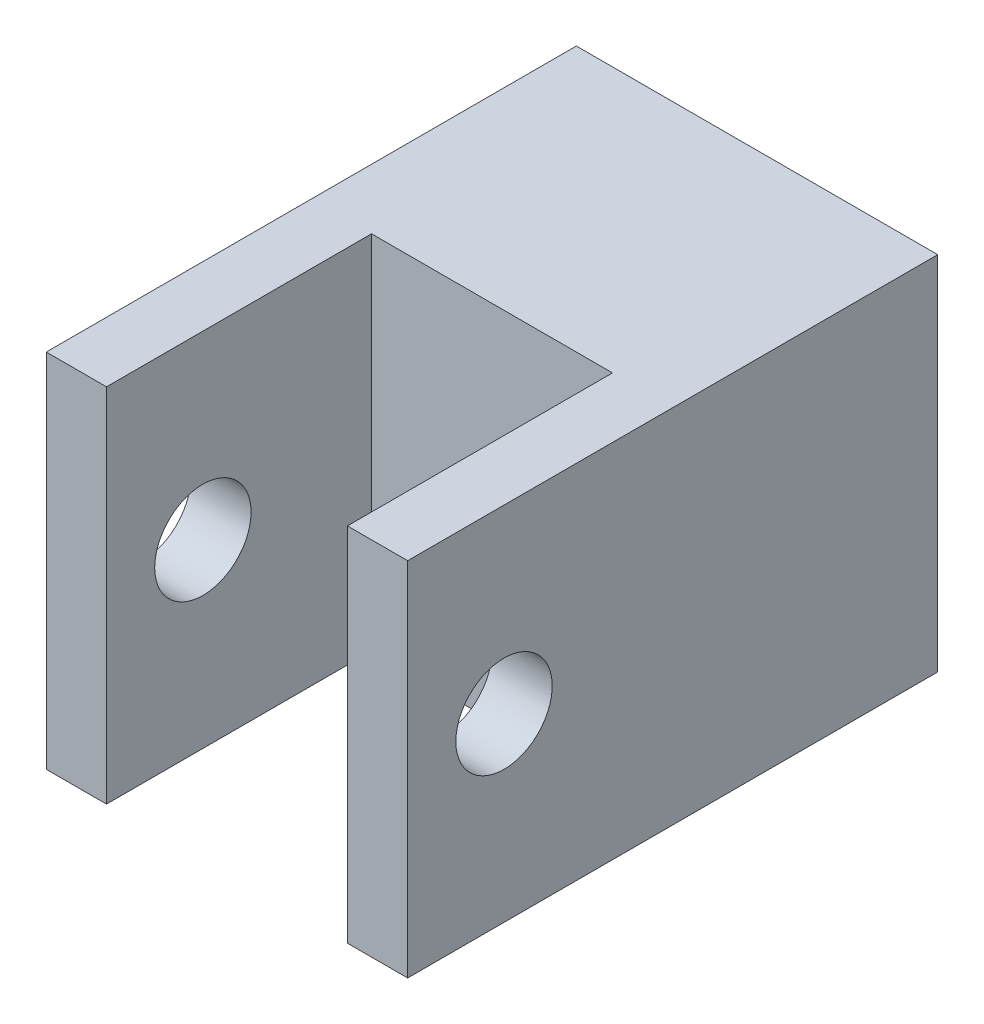
from build123d import *

# Parameters (mm, degrees)
SKETCH2_W           = 15
SKETCH2_H           = 15
BOSS_EXTRUDE2_DEPTH = 22
SKETCH4_W           = 10
SKETCH4_H           = 15
CUT_EXTRUDE1_DEPTH  = 11
SKETCH5_R           = 2
CUT_EXTRUDE2_DEPTH  = 25


with BuildPart() as part:
    # Sketch2 → Boss-Extrude2 (new body)
    with BuildSketch(Plane.XY):
        Rectangle(SKETCH2_W, SKETCH2_H)
    extrude(amount=BOSS_EXTRUDE2_DEPTH)

    # Sketch4 → Cut-Extrude1 (cut)
    with BuildSketch(Plane.XY.offset(22)):
        Rectangle(SKETCH4_W, SKETCH4_H)
    extrude(amount=-CUT_EXTRUDE1_DEPTH, mode=Mode.SUBTRACT)

    # Sketch5 → Cut-Extrude2 (cut)
    with BuildSketch(Plane.ZY.offset(7.5)):
        with Locations((18, 0)):
            Circle(SKETCH5_R)
    extrude(amount=-CUT_EXTRUDE2_DEPTH, mode=Mode.SUBTRACT)


solid = part.part
